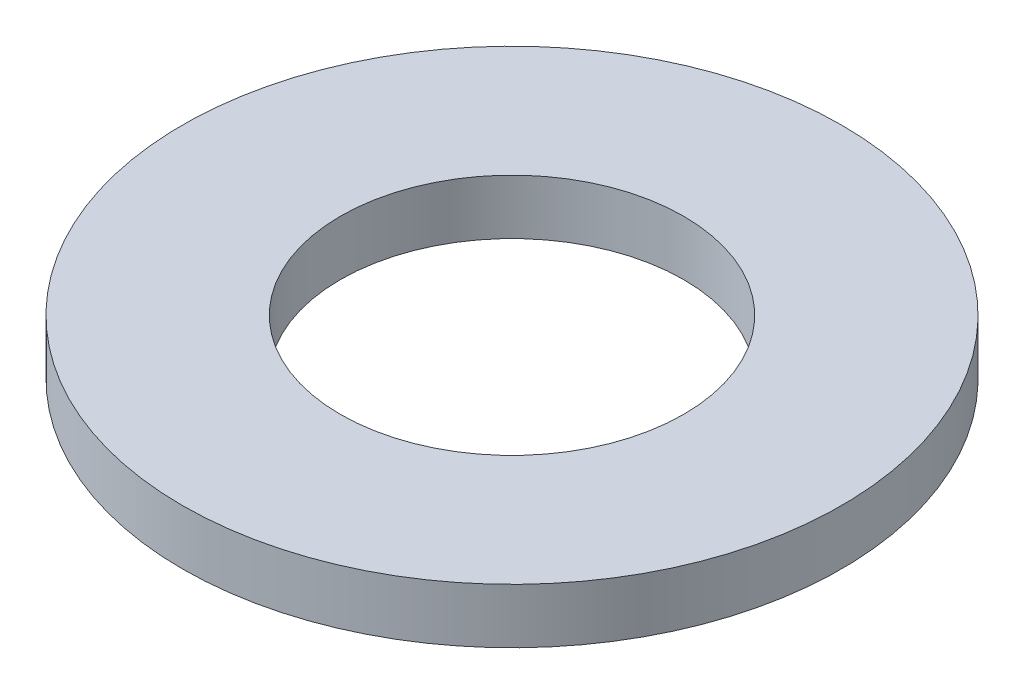
from build123d import *

# Parameters (mm, degrees)
SKETCH1_R           = 6
SKETCH1_R_2         = 3.125
BOSS_EXTRUDE1_DEPTH = 1


with BuildPart() as part:
    # Sketch1 → Boss-Extrude1 (new body)
    with BuildSketch(Plane(origin=(0, 0, 0), x_dir=(1, 0, 0), z_dir=(0, 1, 0))):
        Circle(SKETCH1_R)
        Circle(SKETCH1_R_2, mode=Mode.SUBTRACT)
    extrude(amount=BOSS_EXTRUDE1_DEPTH)


solid = part.part
